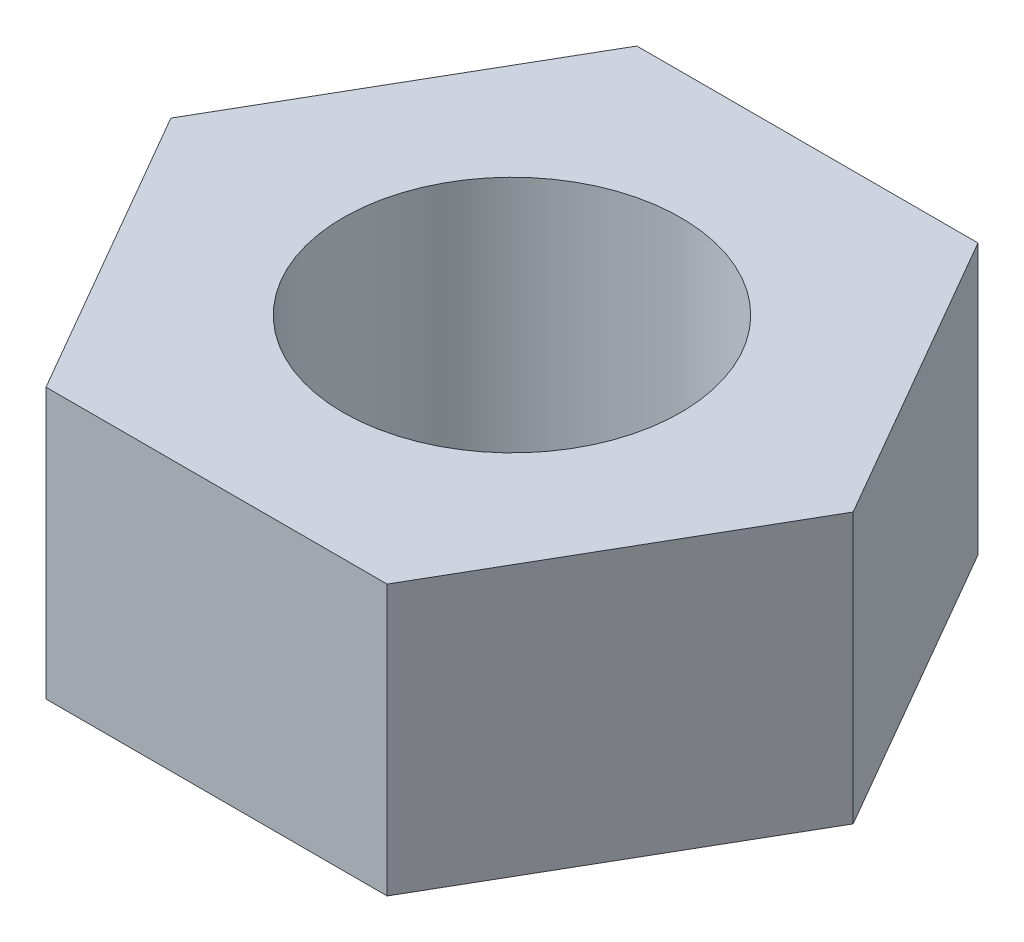
from build123d import *

# Parameters (mm, degrees)
SKETCH1_R           = 2
BOSS_EXTRUDE1_DEPTH = 3.2


with BuildPart() as part:
    # Sketch1 → Boss-Extrude1 (new body)
    with BuildSketch(Plane(origin=(0, 0, 0), x_dir=(1, 0, 0), z_dir=(0, 1, 0))):
        Polygon((4.041451884, 0), (2.020725942, 3.5), (-2.020725942, 3.5), (-4.041451884, 0), (-2.020725942, -3.5), (2.020725942, -3.5), align=None)
        Circle(SKETCH1_R, mode=Mode.SUBTRACT)
    extrude(amount=BOSS_EXTRUDE1_DEPTH)


solid = part.part
